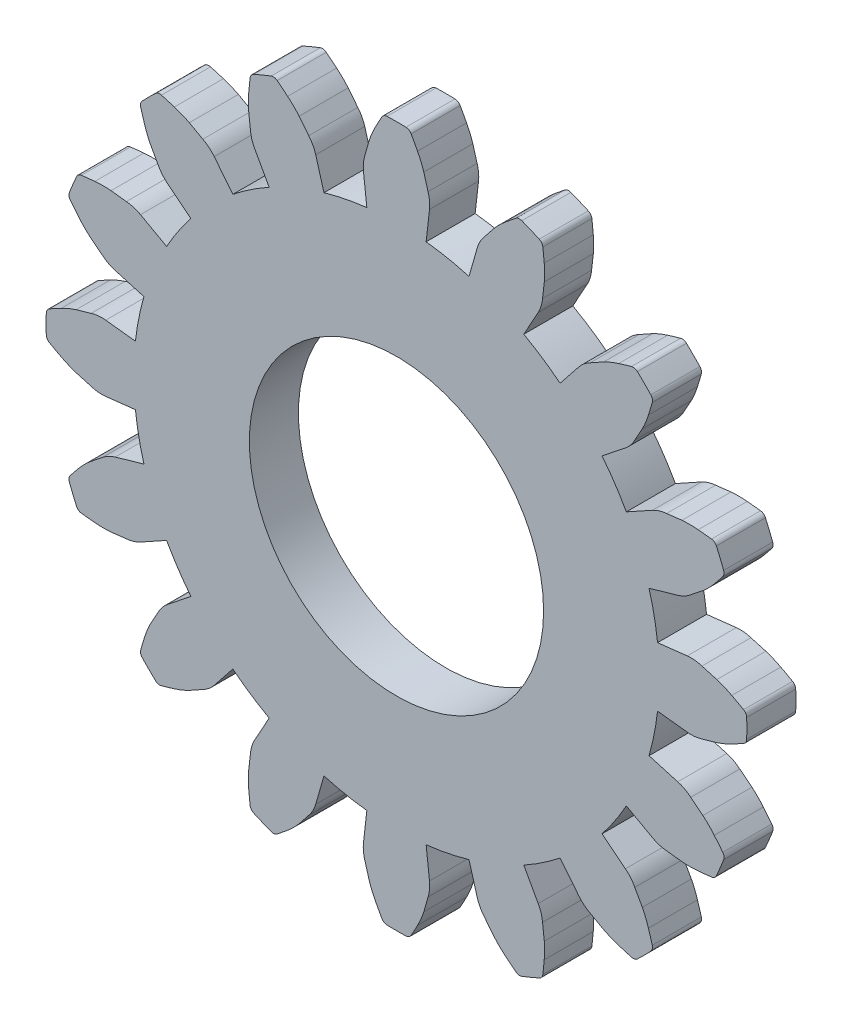
from build123d import *

# Parameters (mm, degrees)
MODEL_R             = 6
BOSS_EXTRUDE1_DEPTH = 2


with BuildPart() as part:
    # Model → Boss-Extrude1 (new body)
    with BuildSketch(Plane.XY):
        with BuildLine():
            Line((26.782722792, 18.011824951), (27.993412141, 18.149315203))
            ThreePointArc((27.993412141, 18.149315203), (28.295681743, 18.151460367), (28.591640535, 18.089979414))
            ThreePointArc((28.591640535, 18.089979414), (28.895268754, 18.003567329), (29.198884101, 17.917110032))
            ThreePointArc((29.198884101, 17.917110032), (29.508898725, 17.802322588), (29.807766952, 17.661032083))
            ThreePointArc((29.807766952, 17.661032083), (30.049498055, 17.531965853), (30.289739393, 17.40014735))
            ThreePointArc((30.289739393, 17.40014735), (30.381758809, 17.311523904), (30.41781219, 17.188960279))
            ThreePointArc((30.41781219, 17.188960279), (30.421728943, 16.995843706), (30.423034607, 16.802691831))
            ThreePointArc((30.423034607, 16.802691831), (30.421728943, 16.609539955), (30.41781219, 16.416423382))
            ThreePointArc((30.41781219, 16.416423382), (30.381758809, 16.293859758), (30.289739393, 16.205236312))
            ThreePointArc((30.289739393, 16.205236312), (30.049498055, 16.073417809), (29.807766952, 15.944351579))
            ThreePointArc((29.807766952, 15.944351579), (29.508898725, 15.803061074), (29.198884101, 15.68827363))
            ThreePointArc((29.198884101, 15.68827363), (28.895268754, 15.601816332), (28.591640535, 15.515404247))
            ThreePointArc((28.591640535, 15.515404247), (28.295681743, 15.453923294), (27.993412141, 15.456068458))
            Line((27.993412141, 15.456068458), (26.782722792, 15.59355871))
            ThreePointArc((26.782722792, 15.59355871), (26.723167784, 15.151436895), (26.645261878, 14.712177099))
            ThreePointArc((26.645261878, 14.712177099), (26.549140103, 14.276540664), (26.434969063, 13.845282653))
            Line((26.434969063, 13.845282653), (27.606115414, 13.508996328))
            ThreePointArc((27.606115414, 13.508996328), (27.886197031, 13.395304632), (28.13609956, 13.225245112))
            ThreePointArc((28.13609956, 13.225245112), (28.383546983, 13.029217266), (28.630965213, 12.833152575))
            ThreePointArc((28.630965213, 12.833152575), (28.873454126, 12.608465345), (29.095502828, 12.36355802))
            ThreePointArc((29.095502828, 12.36355802), (29.269441739, 12.151809883), (29.440951037, 11.938089087))
            ThreePointArc((29.440951037, 11.938089087), (29.492051167, 11.820997392), (29.478457079, 11.693966337))
            ThreePointArc((29.478457079, 11.693966337), (29.408173175, 11.514051011), (29.335463428, 11.335102291))
            ThreePointArc((29.335463428, 11.335102291), (29.260341129, 11.157152882), (29.182820008, 10.98023531))
            ThreePointArc((29.182820008, 10.98023531), (29.102607959, 10.880798317), (28.983678379, 10.834135235))
            ThreePointArc((28.983678379, 10.834135235), (28.711279567, 10.804287198), (28.43855764, 10.777552038))
            ThreePointArc((28.43855764, 10.777552038), (28.108369867, 10.761388551), (27.778026448, 10.773976242))
            ThreePointArc((27.778026448, 10.773976242), (27.464436668, 10.810288678), (27.150852298, 10.84664781))
            ThreePointArc((27.150852298, 10.84664781), (26.853894286, 10.903105342), (26.575454506, 11.020760784))
            Line((26.575454506, 11.020760784), (25.509538637, 11.611095969))
            ThreePointArc((25.509538637, 11.611095969), (25.28532429, 11.225419388), (25.045251172, 10.849409553))
            ThreePointArc((25.045251172, 10.849409553), (24.789735386, 10.483718178), (24.519219802, 10.128979094))
            Line((24.519219802, 10.128979094), (25.472526741, 9.370112735))
            ThreePointArc((25.472526741, 9.370112735), (25.687780486, 9.157892709), (25.853581356, 8.905144642))
            ThreePointArc((25.853581356, 8.905144642), (26.007176357, 8.629344498), (26.160730286, 8.353521486))
            ThreePointArc((26.160730286, 8.353521486), (26.298776749, 8.053141063), (26.410201025, 7.741901839))
            ThreePointArc((26.410201025, 7.741901839), (26.489867121, 7.47970853), (26.566533643, 7.216622493))
            ThreePointArc((26.566533643, 7.216622493), (26.568934956, 7.0888887), (26.507762976, 6.976729541))
            ThreePointArc((26.507762976, 6.976729541), (26.373978501, 6.83740594), (26.238322744, 6.699903695))
            ThreePointArc((26.238322744, 6.699903695), (26.100820499, 6.564247938), (25.961496897, 6.430463462))
            ThreePointArc((25.961496897, 6.430463462), (25.849337738, 6.369291482), (25.721603945, 6.371692796))
            ThreePointArc((25.721603945, 6.371692796), (25.458517908, 6.448359317), (25.196324599, 6.528025413))
            ThreePointArc((25.196324599, 6.528025413), (24.885085375, 6.639449689), (24.584704952, 6.777496152))
            ThreePointArc((24.584704952, 6.777496152), (24.30888194, 6.931050082), (24.033081796, 7.084645082))
            ThreePointArc((24.033081796, 7.084645082), (23.780333729, 7.250445953), (23.568113704, 7.465699698))
            Line((23.568113704, 7.465699698), (22.809247345, 8.419006636))
            ThreePointArc((22.809247345, 8.419006636), (22.454508261, 8.148491053), (22.088816886, 7.892975266))
            ThreePointArc((22.088816886, 7.892975266), (21.71280705, 7.652902148), (21.327130469, 7.428687801))
            Line((21.327130469, 7.428687801), (21.917465655, 6.362771933))
            ThreePointArc((21.917465655, 6.362771933), (22.035121096, 6.084332153), (22.091578629, 5.78737414))
            ThreePointArc((22.091578629, 5.78737414), (22.127937761, 5.473789771), (22.164250196, 5.16019999))
            ThreePointArc((22.164250196, 5.16019999), (22.176837887, 4.829856571), (22.1606744, 4.499668798))
            ThreePointArc((22.1606744, 4.499668798), (22.13393924, 4.226946871), (22.104091203, 3.954548059))
            ThreePointArc((22.104091203, 3.954548059), (22.057428121, 3.835618479), (21.957991128, 3.755406431))
            ThreePointArc((21.957991128, 3.755406431), (21.781073556, 3.677885309), (21.603124147, 3.60276301))
            ThreePointArc((21.603124147, 3.60276301), (21.424175427, 3.530053264), (21.244260101, 3.459769359))
            ThreePointArc((21.244260101, 3.459769359), (21.117229046, 3.446175271), (21.000137352, 3.497275402))
            ThreePointArc((21.000137352, 3.497275402), (20.786416555, 3.668784699), (20.574668418, 3.84272361))
            ThreePointArc((20.574668418, 3.84272361), (20.329761093, 4.064772313), (20.105073863, 4.307261225))
            ThreePointArc((20.105073863, 4.307261225), (19.909009172, 4.554679455), (19.712981327, 4.802126879))
            ThreePointArc((19.712981327, 4.802126879), (19.542921807, 5.052029407), (19.429230111, 5.332111024))
            Line((19.429230111, 5.332111024), (19.092943785, 6.503257376))
            ThreePointArc((19.092943785, 6.503257376), (18.661685774, 6.389086335), (18.226049339, 6.29296456))
            ThreePointArc((18.226049339, 6.29296456), (17.786789543, 6.215058654), (17.344667728, 6.155503646))
            Line((17.344667728, 6.155503646), (17.48215798, 4.944814297))
            ThreePointArc((17.48215798, 4.944814297), (17.484303144, 4.642544695), (17.422822191, 4.346585903))
            ThreePointArc((17.422822191, 4.346585903), (17.336410106, 4.042957685), (17.249952808, 3.739342337))
            ThreePointArc((17.249952808, 3.739342337), (17.135165365, 3.429327713), (16.99387486, 3.130459486))
            ThreePointArc((16.99387486, 3.130459486), (16.86480863, 2.888728383), (16.732990126, 2.648487045))
            ThreePointArc((16.732990126, 2.648487045), (16.64436668, 2.556467629), (16.521803056, 2.520414249))
            ThreePointArc((16.521803056, 2.520414249), (16.328686483, 2.516497495), (16.135534607, 2.515191831))
            ThreePointArc((16.135534607, 2.515191831), (15.942382732, 2.516497495), (15.749266159, 2.520414249))
            ThreePointArc((15.749266159, 2.520414249), (15.626702535, 2.556467629), (15.538079088, 2.648487045))
            ThreePointArc((15.538079088, 2.648487045), (15.406260585, 2.888728383), (15.277194355, 3.130459486))
            ThreePointArc((15.277194355, 3.130459486), (15.13590385, 3.429327713), (15.021116407, 3.739342337))
            ThreePointArc((15.021116407, 3.739342337), (14.934659109, 4.042957685), (14.848247024, 4.346585903))
            ThreePointArc((14.848247024, 4.346585903), (14.786766071, 4.642544695), (14.788911235, 4.944814297))
            Line((14.788911235, 4.944814297), (14.926401487, 6.155503646))
            ThreePointArc((14.926401487, 6.155503646), (14.484279672, 6.215058654), (14.045019876, 6.29296456))
            ThreePointArc((14.045019876, 6.29296456), (13.609383441, 6.389086335), (13.17812543, 6.503257376))
            Line((13.17812543, 6.503257376), (12.841839104, 5.332111024))
            ThreePointArc((12.841839104, 5.332111024), (12.728147408, 5.052029407), (12.558087888, 4.802126879))
            ThreePointArc((12.558087888, 4.802126879), (12.362060043, 4.554679455), (12.165995352, 4.307261225))
            ThreePointArc((12.165995352, 4.307261225), (11.941308122, 4.064772313), (11.696400797, 3.84272361))
            ThreePointArc((11.696400797, 3.84272361), (11.48465266, 3.668784699), (11.270931863, 3.497275402))
            ThreePointArc((11.270931863, 3.497275402), (11.153840169, 3.446175271), (11.026809114, 3.459769359))
            ThreePointArc((11.026809114, 3.459769359), (10.846893788, 3.530053264), (10.667945068, 3.60276301))
            ThreePointArc((10.667945068, 3.60276301), (10.489995659, 3.677885309), (10.313078087, 3.755406431))
            ThreePointArc((10.313078087, 3.755406431), (10.213641094, 3.835618479), (10.166978012, 3.954548059))
            ThreePointArc((10.166978012, 3.954548059), (10.137129975, 4.226946871), (10.110394815, 4.499668798))
            ThreePointArc((10.110394815, 4.499668798), (10.094231328, 4.829856571), (10.106819019, 5.16019999))
            ThreePointArc((10.106819019, 5.16019999), (10.143131454, 5.47378977), (10.179490586, 5.78737414))
            ThreePointArc((10.179490586, 5.78737414), (10.235948119, 6.084332153), (10.35360356, 6.362771933))
            Line((10.35360356, 6.362771933), (10.943938746, 7.428687801))
            ThreePointArc((10.943938746, 7.428687801), (10.558262165, 7.652902148), (10.182252329, 7.892975266))
            ThreePointArc((10.182252329, 7.892975266), (9.816560954, 8.148491053), (9.46182187, 8.419006636))
            Line((9.46182187, 8.419006636), (8.702955511, 7.465699698))
            ThreePointArc((8.702955511, 7.465699698), (8.490735486, 7.250445953), (8.237987419, 7.084645082))
            ThreePointArc((8.237987419, 7.084645082), (7.962187275, 6.931050082), (7.686364262, 6.777496152))
            ThreePointArc((7.686364262, 6.777496152), (7.38598384, 6.639449689), (7.074744616, 6.528025413))
            ThreePointArc((7.074744616, 6.528025413), (6.812551307, 6.448359317), (6.54946527, 6.371692796))
            ThreePointArc((6.54946527, 6.371692796), (6.421731477, 6.369291482), (6.309572318, 6.430463462))
            ThreePointArc((6.309572318, 6.430463462), (6.170248716, 6.564247938), (6.032746471, 6.699903695))
            ThreePointArc((6.032746471, 6.699903695), (5.897090714, 6.83740594), (5.763306239, 6.976729541))
            ThreePointArc((5.763306239, 6.976729541), (5.702134259, 7.0888887), (5.704535572, 7.216622493))
            ThreePointArc((5.704535572, 7.216622493), (5.781202094, 7.47970853), (5.86086819, 7.741901839))
            ThreePointArc((5.86086819, 7.741901839), (5.972292466, 8.053141063), (6.110338929, 8.353521486))
            ThreePointArc((6.110338929, 8.353521486), (6.263892858, 8.629344498), (6.417487859, 8.905144642))
            ThreePointArc((6.417487859, 8.905144642), (6.583288729, 9.157892709), (6.798542474, 9.370112735))
            Line((6.798542474, 9.370112735), (7.751849413, 10.128979094))
            ThreePointArc((7.751849413, 10.128979094), (7.481333829, 10.483718178), (7.225818043, 10.849409553))
            ThreePointArc((7.225818043, 10.849409553), (6.985744925, 11.225419388), (6.761530578, 11.611095969))
            Line((6.761530578, 11.611095969), (5.695614709, 11.020760784))
            ThreePointArc((5.695614709, 11.020760784), (5.417174929, 10.903105342), (5.120216917, 10.84664781))
            ThreePointArc((5.120216917, 10.84664781), (4.806632547, 10.810288677), (4.493042766, 10.773976242))
            ThreePointArc((4.493042766, 10.773976242), (4.162699348, 10.761388551), (3.832511574, 10.777552038))
            ThreePointArc((3.832511574, 10.777552038), (3.559789648, 10.804287198), (3.287390836, 10.834135235))
            ThreePointArc((3.287390836, 10.834135235), (3.168461256, 10.880798317), (3.088249207, 10.98023531))
            ThreePointArc((3.088249207, 10.98023531), (3.010728086, 11.157152882), (2.935605787, 11.335102291))
            ThreePointArc((2.935605787, 11.335102291), (2.86289604, 11.514051011), (2.792612136, 11.693966337))
            ThreePointArc((2.792612136, 11.693966337), (2.779018048, 11.820997392), (2.830118178, 11.938089087))
            ThreePointArc((2.830118178, 11.938089087), (3.001627476, 12.151809883), (3.175566387, 12.36355802))
            ThreePointArc((3.175566387, 12.36355802), (3.397615089, 12.608465345), (3.640104002, 12.833152575))
            ThreePointArc((3.640104002, 12.833152575), (3.887522232, 13.029217266), (4.134969655, 13.225245111))
            ThreePointArc((4.134969655, 13.225245111), (4.384872183, 13.395304632), (4.664953801, 13.508996328))
            Line((4.664953801, 13.508996328), (5.836100152, 13.845282653))
            ThreePointArc((5.836100152, 13.845282653), (5.721929112, 14.276540664), (5.625807337, 14.712177099))
            ThreePointArc((5.625807337, 14.712177099), (5.547901431, 15.151436895), (5.488346423, 15.59355871))
            Line((5.488346423, 15.59355871), (4.277657074, 15.456068458))
            ThreePointArc((4.277657074, 15.456068458), (3.975387472, 15.453923294), (3.67942868, 15.515404247))
            ThreePointArc((3.67942868, 15.515404247), (3.375800461, 15.601816332), (3.072185114, 15.68827363))
            ThreePointArc((3.072185114, 15.68827363), (2.76217049, 15.803061074), (2.463302263, 15.944351579))
            ThreePointArc((2.463302263, 15.944351579), (2.22157116, 16.073417809), (1.981329822, 16.205236312))
            ThreePointArc((1.981329822, 16.205236312), (1.889310406, 16.293859758), (1.853257025, 16.416423382))
            ThreePointArc((1.853257025, 16.416423382), (1.849340272, 16.609539955), (1.848034607, 16.802691831))
            ThreePointArc((1.848034607, 16.802691831), (1.849340272, 16.995843706), (1.853257025, 17.188960279))
            ThreePointArc((1.853257025, 17.188960279), (1.889310406, 17.311523904), (1.981329822, 17.40014735))
            ThreePointArc((1.981329822, 17.40014735), (2.22157116, 17.531965853), (2.463302263, 17.661032083))
            ThreePointArc((2.463302263, 17.661032083), (2.76217049, 17.802322588), (3.072185114, 17.917110032))
            ThreePointArc((3.072185114, 17.917110032), (3.375800461, 18.003567329), (3.67942868, 18.089979414))
            ThreePointArc((3.67942868, 18.089979414), (3.975387472, 18.151460367), (4.277657074, 18.149315203))
            Line((4.277657074, 18.149315203), (5.488346423, 18.011824951))
            ThreePointArc((5.488346423, 18.011824951), (5.547901431, 18.453946767), (5.625807337, 18.893206563))
            ThreePointArc((5.625807337, 18.893206563), (5.721929112, 19.328842997), (5.836100152, 19.760101008))
            Line((5.836100152, 19.760101008), (4.664953801, 20.096387334))
            ThreePointArc((4.664953801, 20.096387334), (4.384872183, 20.21007903), (4.134969655, 20.38013855))
            ThreePointArc((4.134969655, 20.38013855), (3.887522232, 20.576166396), (3.640104002, 20.772231087))
            ThreePointArc((3.640104002, 20.772231087), (3.397615089, 20.996918317), (3.175566387, 21.241825642))
            ThreePointArc((3.175566387, 21.241825642), (3.001627476, 21.453573778), (2.830118178, 21.667294575))
            ThreePointArc((2.830118178, 21.667294575), (2.779018048, 21.784386269), (2.792612136, 21.911417324))
            ThreePointArc((2.792612136, 21.911417324), (2.86289604, 22.09133265), (2.935605787, 22.270281371))
            ThreePointArc((2.935605787, 22.270281371), (3.010728086, 22.448230779), (3.088249207, 22.625148352))
            ThreePointArc((3.088249207, 22.625148352), (3.168461256, 22.724585344), (3.287390836, 22.771248426))
            ThreePointArc((3.287390836, 22.771248426), (3.559789648, 22.801096463), (3.832511574, 22.827831623))
            ThreePointArc((3.832511574, 22.827831623), (4.162699348, 22.84399511), (4.493042766, 22.83140742))
            ThreePointArc((4.493042766, 22.83140742), (4.806632547, 22.795094984), (5.120216917, 22.758735852))
            ThreePointArc((5.120216917, 22.758735852), (5.417174929, 22.70227832), (5.695614709, 22.584622878))
            Line((5.695614709, 22.584622878), (6.761530578, 21.994287692))
            ThreePointArc((6.761530578, 21.994287692), (6.985744925, 22.379964273), (7.225818043, 22.755974109))
            ThreePointArc((7.225818043, 22.755974109), (7.481333829, 23.121665484), (7.751849413, 23.476404568))
            Line((7.751849413, 23.476404568), (6.798542474, 24.235270927))
            ThreePointArc((6.798542474, 24.235270927), (6.583288729, 24.447490952), (6.417487859, 24.70023902))
            ThreePointArc((6.417487859, 24.70023902), (6.263892858, 24.976039163), (6.110338929, 25.251862176))
            ThreePointArc((6.110338929, 25.251862176), (5.972292466, 25.552242598), (5.86086819, 25.863481823))
            ThreePointArc((5.86086819, 25.863481823), (5.781202094, 26.125675132), (5.704535572, 26.388761168))
            ThreePointArc((5.704535572, 26.388761168), (5.702134259, 26.516494961), (5.763306239, 26.628654121))
            ThreePointArc((5.763306239, 26.628654121), (5.897090714, 26.767977722), (6.032746471, 26.905479967))
            ThreePointArc((6.032746471, 26.905479967), (6.170248716, 27.041135724), (6.309572318, 27.174920199))
            ThreePointArc((6.309572318, 27.174920199), (6.421731477, 27.236092179), (6.54946527, 27.233690866))
            ThreePointArc((6.54946527, 27.233690866), (6.812551307, 27.157024344), (7.074744616, 27.077358248))
            ThreePointArc((7.074744616, 27.077358248), (7.38598384, 26.965933973), (7.686364262, 26.82788751))
            ThreePointArc((7.686364262, 26.82788751), (7.962187275, 26.67433358), (8.237987419, 26.520738579))
            ThreePointArc((8.237987419, 26.520738579), (8.490735486, 26.354937709), (8.702955511, 26.139683964))
            Line((8.702955511, 26.139683964), (9.46182187, 25.186377025))
            ThreePointArc((9.46182187, 25.186377025), (9.816560954, 25.456892609), (10.182252329, 25.712408395))
            ThreePointArc((10.182252329, 25.712408395), (10.558262165, 25.952481514), (10.943938746, 26.176695861))
            Line((10.943938746, 26.176695861), (10.35360356, 27.242611729))
            ThreePointArc((10.35360356, 27.242611729), (10.235948119, 27.521051509), (10.179490586, 27.818009521))
            ThreePointArc((10.179490586, 27.818009521), (10.143131454, 28.131593891), (10.106819019, 28.445183672))
            ThreePointArc((10.106819019, 28.445183672), (10.094231328, 28.77552709), (10.110394815, 29.105714864))
            ThreePointArc((10.110394815, 29.105714864), (10.137129975, 29.378436791), (10.166978012, 29.650835603))
            ThreePointArc((10.166978012, 29.650835603), (10.213641094, 29.769765182), (10.313078087, 29.849977231))
            ThreePointArc((10.313078087, 29.849977231), (10.489995659, 29.927498352), (10.667945068, 30.002620652))
            ThreePointArc((10.667945068, 30.002620652), (10.846893788, 30.075330398), (11.026809114, 30.145614302))
            ThreePointArc((11.026809114, 30.145614302), (11.153840169, 30.159208391), (11.270931863, 30.10810826))
            ThreePointArc((11.270931863, 30.10810826), (11.48465266, 29.936598962), (11.696400797, 29.762660051))
            ThreePointArc((11.696400797, 29.762660051), (11.941308122, 29.540611349), (12.165995352, 29.298122436))
            ThreePointArc((12.165995352, 29.298122436), (12.362060043, 29.050704206), (12.558087888, 28.803256783))
            ThreePointArc((12.558087888, 28.803256783), (12.728147408, 28.553354255), (12.841839104, 28.273272638))
            Line((12.841839104, 28.273272638), (13.17812543, 27.102126286))
            ThreePointArc((13.17812543, 27.102126286), (13.609383441, 27.216297327), (14.045019876, 27.312419101))
            ThreePointArc((14.045019876, 27.312419101), (14.484279672, 27.390325007), (14.926401487, 27.449880015))
            Line((14.926401487, 27.449880015), (14.788911235, 28.660569365))
            ThreePointArc((14.788911235, 28.660569365), (14.786766071, 28.962838967), (14.848247024, 29.258797758))
            ThreePointArc((14.848247024, 29.258797758), (14.934659109, 29.562425977), (15.021116407, 29.866041324))
            ThreePointArc((15.021116407, 29.866041324), (15.13590385, 30.176055948), (15.277194355, 30.474924175))
            ThreePointArc((15.277194355, 30.474924175), (15.406260585, 30.716655279), (15.538079088, 30.956896616))
            ThreePointArc((15.538079088, 30.956896616), (15.626702535, 31.048916033), (15.749266159, 31.084969413))
            ThreePointArc((15.749266159, 31.084969413), (15.942382732, 31.088886167), (16.135534607, 31.090191831))
            ThreePointArc((16.135534607, 31.090191831), (16.328686483, 31.088886167), (16.521803056, 31.084969413))
            ThreePointArc((16.521803056, 31.084969413), (16.64436668, 31.048916033), (16.732990126, 30.956896616))
            ThreePointArc((16.732990126, 30.956896616), (16.86480863, 30.716655279), (16.99387486, 30.474924175))
            ThreePointArc((16.99387486, 30.474924175), (17.135165365, 30.176055948), (17.249952808, 29.866041324))
            ThreePointArc((17.249952808, 29.866041324), (17.336410106, 29.562425977), (17.422822191, 29.258797758))
            ThreePointArc((17.422822191, 29.258797758), (17.484303144, 28.962838967), (17.48215798, 28.660569365))
            Line((17.48215798, 28.660569365), (17.344667728, 27.449880015))
            ThreePointArc((17.344667728, 27.449880015), (17.786789543, 27.390325007), (18.226049339, 27.312419101))
            ThreePointArc((18.226049339, 27.312419101), (18.661685774, 27.216297327), (19.092943785, 27.102126286))
            Line((19.092943785, 27.102126286), (19.429230111, 28.273272638))
            ThreePointArc((19.429230111, 28.273272638), (19.542921807, 28.553354255), (19.712981327, 28.803256783))
            ThreePointArc((19.712981327, 28.803256783), (19.909009172, 29.050704206), (20.105073863, 29.298122436))
            ThreePointArc((20.105073863, 29.298122436), (20.329761093, 29.540611349), (20.574668418, 29.762660051))
            ThreePointArc((20.574668418, 29.762660051), (20.786416555, 29.936598962), (21.000137352, 30.10810826))
            ThreePointArc((21.000137352, 30.10810826), (21.117229046, 30.159208391), (21.244260101, 30.145614302))
            ThreePointArc((21.244260101, 30.145614302), (21.424175427, 30.075330398), (21.603124147, 30.002620652))
            ThreePointArc((21.603124147, 30.002620652), (21.781073556, 29.927498352), (21.957991128, 29.849977231))
            ThreePointArc((21.957991128, 29.849977231), (22.057428121, 29.769765182), (22.104091203, 29.650835603))
            ThreePointArc((22.104091203, 29.650835603), (22.13393924, 29.378436791), (22.1606744, 29.105714864))
            ThreePointArc((22.1606744, 29.105714864), (22.176837887, 28.77552709), (22.164250196, 28.445183672))
            ThreePointArc((22.164250196, 28.445183672), (22.127937761, 28.131593891), (22.091578629, 27.818009521))
            ThreePointArc((22.091578629, 27.818009521), (22.035121096, 27.521051509), (21.917465655, 27.242611729))
            Line((21.917465655, 27.242611729), (21.327130469, 26.176695861))
            ThreePointArc((21.327130469, 26.176695861), (21.71280705, 25.952481514), (22.088816886, 25.712408395))
            ThreePointArc((22.088816886, 25.712408395), (22.454508261, 25.456892609), (22.809247345, 25.186377025))
            Line((22.809247345, 25.186377025), (23.568113704, 26.139683964))
            ThreePointArc((23.568113704, 26.139683964), (23.780333729, 26.354937709), (24.033081796, 26.520738579))
            ThreePointArc((24.033081796, 26.520738579), (24.30888194, 26.67433358), (24.584704952, 26.82788751))
            ThreePointArc((24.584704952, 26.82788751), (24.885085375, 26.965933973), (25.196324599, 27.077358248))
            ThreePointArc((25.196324599, 27.077358248), (25.458517908, 27.157024344), (25.721603945, 27.233690866))
            ThreePointArc((25.721603945, 27.233690866), (25.849337738, 27.236092179), (25.961496897, 27.174920199))
            ThreePointArc((25.961496897, 27.174920199), (26.100820499, 27.041135724), (26.238322744, 26.905479967))
            ThreePointArc((26.238322744, 26.905479967), (26.373978501, 26.767977722), (26.507762976, 26.628654121))
            ThreePointArc((26.507762976, 26.628654121), (26.568934956, 26.516494961), (26.566533643, 26.388761168))
            ThreePointArc((26.566533643, 26.388761168), (26.489867121, 26.125675132), (26.410201025, 25.863481823))
            ThreePointArc((26.410201025, 25.863481823), (26.298776749, 25.552242598), (26.160730286, 25.251862176))
            ThreePointArc((26.160730286, 25.251862176), (26.007176357, 24.976039163), (25.853581356, 24.70023902))
            ThreePointArc((25.853581356, 24.70023902), (25.687780486, 24.447490952), (25.472526741, 24.235270927))
            Line((25.472526741, 24.235270927), (24.519219802, 23.476404568))
            ThreePointArc((24.519219802, 23.476404568), (24.789735386, 23.121665484), (25.045251172, 22.755974109))
            ThreePointArc((25.045251172, 22.755974109), (25.28532429, 22.379964273), (25.509538637, 21.994287692))
            Line((25.509538637, 21.994287692), (26.575454506, 22.584622878))
            ThreePointArc((26.575454506, 22.584622878), (26.853894286, 22.70227832), (27.150852298, 22.758735852))
            ThreePointArc((27.150852298, 22.758735852), (27.464436668, 22.795094984), (27.778026448, 22.83140742))
            ThreePointArc((27.778026448, 22.83140742), (28.108369867, 22.84399511), (28.43855764, 22.827831623))
            ThreePointArc((28.43855764, 22.827831623), (28.711279567, 22.801096463), (28.983678379, 22.771248426))
            ThreePointArc((28.983678379, 22.771248426), (29.102607959, 22.724585344), (29.182820008, 22.625148352))
            ThreePointArc((29.182820008, 22.625148352), (29.260341129, 22.448230779), (29.335463428, 22.270281371))
            ThreePointArc((29.335463428, 22.270281371), (29.408173175, 22.09133265), (29.478457079, 21.911417324))
            ThreePointArc((29.478457079, 21.911417324), (29.492051167, 21.784386269), (29.440951037, 21.667294575))
            ThreePointArc((29.440951037, 21.667294575), (29.269441739, 21.453573778), (29.095502828, 21.241825642))
            ThreePointArc((29.095502828, 21.241825642), (28.873454126, 20.996918317), (28.630965213, 20.772231087))
            ThreePointArc((28.630965213, 20.772231087), (28.383546983, 20.576166396), (28.13609956, 20.38013855))
            ThreePointArc((28.13609956, 20.38013855), (27.886197031, 20.21007903), (27.606115414, 20.096387334))
            Line((27.606115414, 20.096387334), (26.434969063, 19.760101008))
            ThreePointArc((26.434969063, 19.760101008), (26.549140103, 19.328842997), (26.645261878, 18.893206563))
            ThreePointArc((26.645261878, 18.893206563), (26.723167784, 18.453946767), (26.782722792, 18.011824951))
        make_face()
        with Locations((16.135534607, 16.802691831)):
            Circle(MODEL_R, mode=Mode.SUBTRACT)
    extrude(amount=BOSS_EXTRUDE1_DEPTH)


solid = part.part
